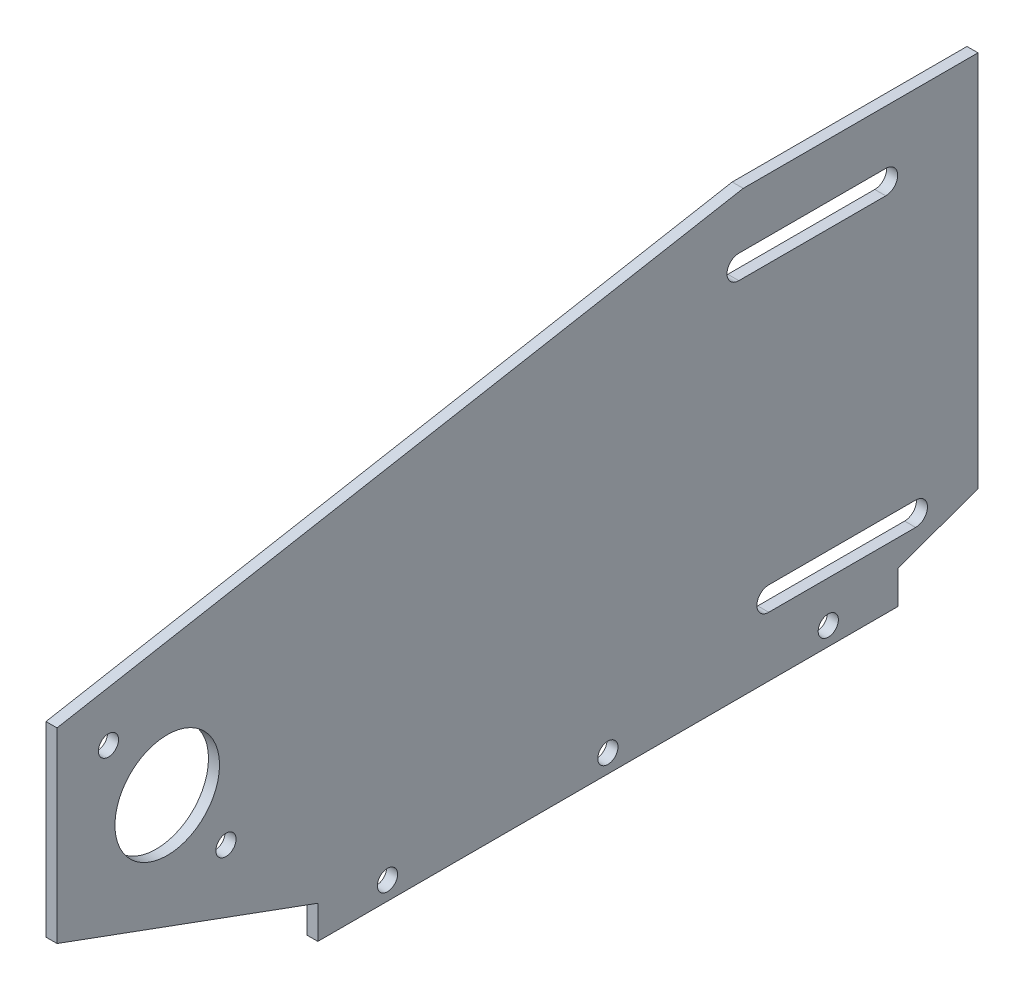
from build123d import *

# Parameters (mm, degrees)
SKETCH1_W           = 300
SKETCH1_H           = 150
SKETCH1_R           = 14.235
BOSS_EXTRUDE1_DEPTH = 3
CUT_EXTRUDE1_REACH  = 5
SKETCH2_R           = 3.225
SKETCH3_R           = 2.75
CUT_EXTRUDE2_DEPTH  = 4
CUT_EXTRUDE3_DEPTH  = 4
CUT_EXTRUDE4_DEPTH  = 10
CUT_EXTRUDE5_DEPTH  = 10
SKETCH7_R           = 2.75
CUT_EXTRUDE6_DEPTH  = 4


with BuildPart() as part:
    # Sketch1 → Boss-Extrude1 (new body)
    with BuildSketch(Plane(origin=(0, 0, 0), x_dir=(0, 0, -1), z_dir=(1, 0, 0))):
        with Locations((150, 75)):
            Rectangle(SKETCH1_W, SKETCH1_H)
        with Locations((30, 55)):
            Circle(SKETCH1_R, mode=Mode.SUBTRACT)
    extrude(amount=BOSS_EXTRUDE1_DEPTH)

    # Sketch2 → Cut-Extrude1 (cut, up to next)
    with BuildSketch(Plane.ZY, mode=Mode.PRIVATE) as cut_extrude1_sk1:
        with Locations((-290, 140)):
            Circle(SKETCH2_R)
    cut_extrude1_tool1 = extrude(cut_extrude1_sk1.sketch, amount=-CUT_EXTRUDE1_REACH, mode=Mode.PRIVATE) & part.part
    add(cut_extrude1_tool1.solids().sort_by_distance((0, 140, -290))[0], mode=Mode.SUBTRACT)
    # Sketch2 → Cut-Extrude1 (cut, up to next)
    with BuildSketch(Plane.ZY, mode=Mode.PRIVATE) as cut_extrude1_sk2:
        with Locations((-10, 110)):
            Circle(SKETCH2_R)
    cut_extrude1_tool2 = extrude(cut_extrude1_sk2.sketch, amount=-CUT_EXTRUDE1_REACH, mode=Mode.PRIVATE) & part.part
    add(cut_extrude1_tool2.solids().sort_by_distance((0, 110, -10))[0], mode=Mode.SUBTRACT)
    # Sketch2 → Cut-Extrude1 (cut, up to next)
    with BuildSketch(Plane.ZY, mode=Mode.PRIVATE) as cut_extrude1_sk3:
        with Locations((-290, 30)):
            Circle(SKETCH2_R)
    cut_extrude1_tool3 = extrude(cut_extrude1_sk3.sketch, amount=-CUT_EXTRUDE1_REACH, mode=Mode.PRIVATE) & part.part
    add(cut_extrude1_tool3.solids().sort_by_distance((0, 30, -290))[0], mode=Mode.SUBTRACT)
    # Sketch2 → Cut-Extrude1 (cut, up to next)
    with BuildSketch(Plane.ZY, mode=Mode.PRIVATE) as cut_extrude1_sk4:
        with BuildLine():
            Line((-185.611446384, 98.478413591), (-225.611446384, 98.478413591))
            ThreePointArc((-225.611446384, 98.478413591), (-228.841446384, 101.708413591), (-225.611446384, 104.938413591))
            Line((-225.611446384, 104.938413591), (-185.611446384, 104.938413591))
            ThreePointArc((-185.611446384, 104.938413591), (-182.381446384, 101.708413591), (-185.611446384, 98.478413591))
        make_face()
    cut_extrude1_tool4 = extrude(cut_extrude1_sk4.sketch, amount=-CUT_EXTRUDE1_REACH, mode=Mode.PRIVATE) & part.part
    add(cut_extrude1_tool4.solids().sort_by_distance((0, 101.708414, -205.611446))[0], mode=Mode.SUBTRACT)
    # Sketch2 → Cut-Extrude1 (cut, up to next)
    with BuildSketch(Plane.ZY, mode=Mode.PRIVATE) as cut_extrude1_sk5:
        with BuildLine():
            Line((-233.743605698, 22.681694356), (-193.743605698, 22.681694356))
            ThreePointArc((-193.743605698, 22.681694356), (-190.518605698, 19.456694356), (-193.743605698, 16.231694356))
            Line((-193.743605698, 16.231694356), (-233.743605698, 16.231694356))
            ThreePointArc((-233.743605698, 16.231694356), (-236.968605698, 19.456694356), (-233.743605698, 22.681694356))
        make_face()
    cut_extrude1_tool5 = extrude(cut_extrude1_sk5.sketch, amount=-CUT_EXTRUDE1_REACH, mode=Mode.PRIVATE) & part.part
    add(cut_extrude1_tool5.solids().sort_by_distance((0, 19.456694, -213.743606))[0], mode=Mode.SUBTRACT)

    # Sketch3 → Cut-Extrude2 (cut, through all)
    with BuildSketch(Plane(origin=(3, 0, 0), x_dir=(0, 0, -1), z_dir=(1, 0, 0))):
        with Locations((14.005743185, 74.73179538)):
            Circle(SKETCH3_R)
        with Locations((45.994256815, 35.26820462)):
            Circle(SKETCH3_R)
    extrude(amount=-CUT_EXTRUDE2_DEPTH, mode=Mode.SUBTRACT)

    # Sketch4 → Cut-Extrude3 (cut, through all)
    with BuildSketch(Plane(origin=(3, 0, 0), x_dir=(0, 0, -1), z_dir=(1, 0, 0))):
        Polygon((71, 9), (0, 35), (0, 0), (71, 0), align=None)
    extrude(amount=-CUT_EXTRUDE3_DEPTH, mode=Mode.SUBTRACT)

    # Sketch5 → Cut-Extrude4 (cut)
    with BuildSketch(Plane(origin=(3, 0, 0), x_dir=(0, 0, -1), z_dir=(1, 0, 0))):
        Polygon((228.92403237, 9), (250.717958721, 16.875947155), (250.717958721, 150), (312.660420977, 150), (312.660420977, -2.829604392), (228.92403237, 0), align=None)
    extrude(amount=-CUT_EXTRUDE4_DEPTH, mode=Mode.SUBTRACT)

    # Sketch6 → Cut-Extrude5 (cut)
    with BuildSketch(Plane(origin=(3, 0, 0), x_dir=(0, 0, -1), z_dir=(1, 0, 0))):
        Polygon((0, 85.848631797), (186.802640374, 119.641480316), (250.717958721, 119.641480316), (250.717958721, 150), (0, 150), align=None)
    extrude(amount=-CUT_EXTRUDE5_DEPTH, mode=Mode.SUBTRACT)

    # Sketch7 → Cut-Extrude6 (cut, through all)
    with BuildSketch(Plane.ZY):
        with Locations((-209.962016185, 5)):
            Circle(SKETCH7_R)
        with Locations((-149.962016185, 5)):
            Circle(SKETCH7_R)
        with Locations((-89.962016185, 5)):
            Circle(SKETCH7_R)
    extrude(amount=-CUT_EXTRUDE6_DEPTH, mode=Mode.SUBTRACT)


solid = part.part
